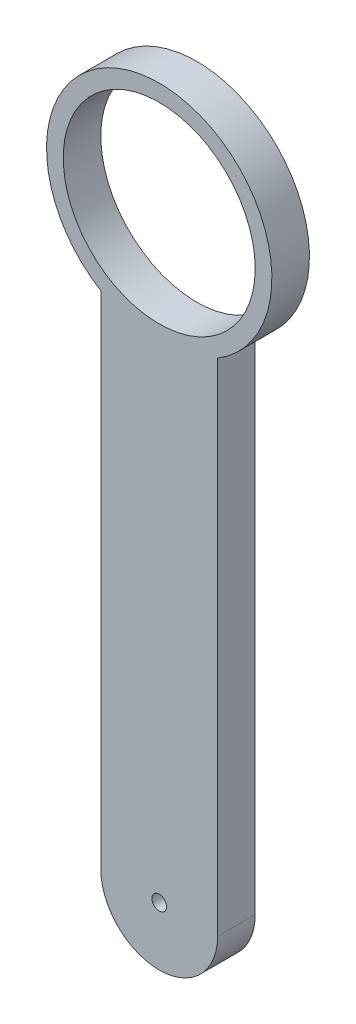
from build123d import *

# Parameters (mm, degrees)
SKETCH_4_R          = 23
EXTRUDE_2_DEPTH     = 9
SKETCH_5_R          = 1.75
CUT_EXTRUDE_1_DEPTH = 10


with BuildPart() as part:
    # 草图4 → 凸台-拉伸2 (new body)
    with BuildSketch(Plane.XY):
        with BuildLine():
            Line((0, 0), (0, 120))
            ThreePointArc((0, 120), (14, 170.086792761), (28, 120))
            Line((28, 120), (28, 0))
            ThreePointArc((28, 0), (14, -14), (0, 0))
        make_face()
        with Locations((14, 143.086792761)):
            Circle(SKETCH_4_R, mode=Mode.SUBTRACT)
    extrude(amount=EXTRUDE_2_DEPTH)

    # 草图5 → 切除-拉伸1 (cut)
    with BuildSketch(Plane(origin=(0, 0, 0), x_dir=(-1, 0, 0), z_dir=(0, 0, -1))):
        with Locations((-14, 0)):
            Circle(SKETCH_5_R)
    extrude(amount=-CUT_EXTRUDE_1_DEPTH, mode=Mode.SUBTRACT)


solid = part.part
